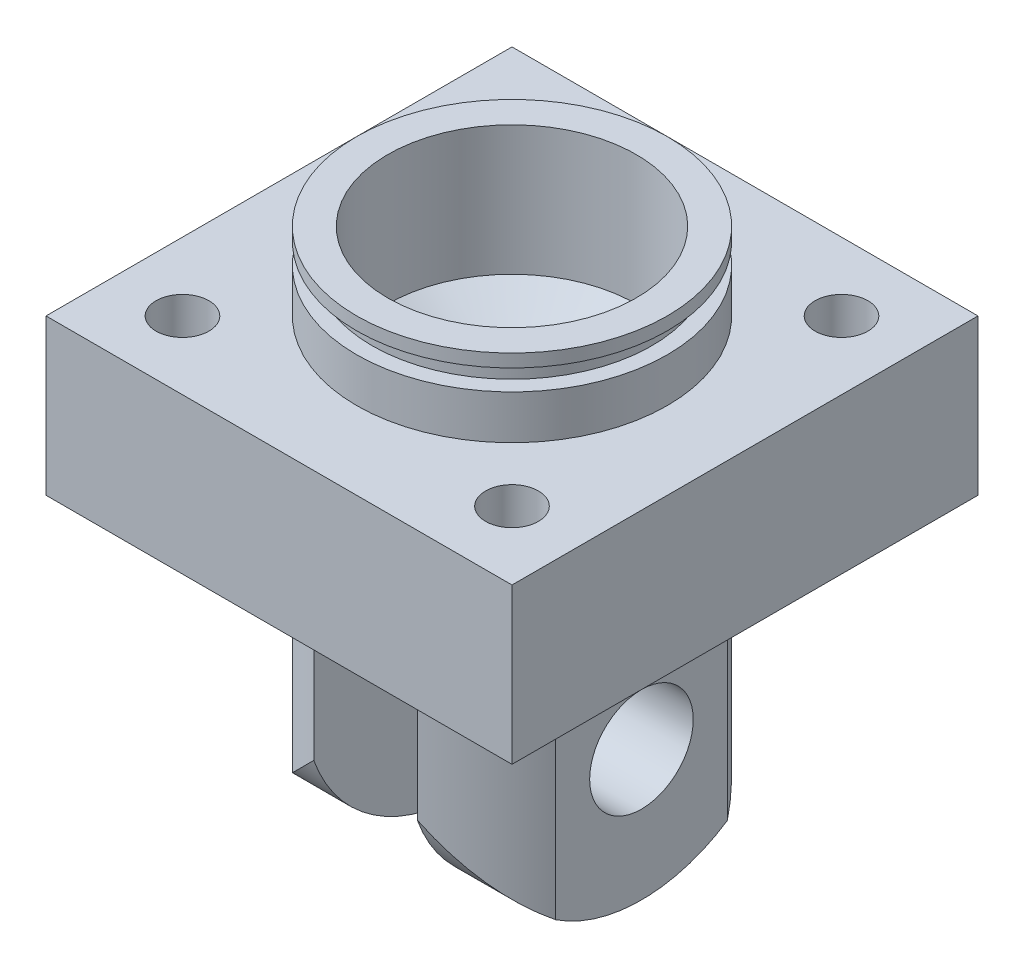
from build123d import *

# Parameters (mm, degrees)
SKETCH1_W                          = 90
SKETCH1_H                          = 90
BOSS_EXTRUDE1_DEPTH                = 15
SKETCH2_R                          = 30
BOSS_EXTRUDE2_DEPTH                = 8.5
SKETCH3_R                          = 27
BOSS_EXTRUDE3_DEPTH                = 4
SKETCH4_R                          = 30
BOSS_EXTRUDE4_DEPTH                = 2.5
BOSS_EXTRUDE5_START                = 55.2
SKETCH5_R                          = 30
BOSS_EXTRUDE5_DEPTH                = 55.2
CUT_EXTRUDE1_DEPTH                 = 95.752519755
CUT_EXTRUDE1_DEPTH_BACK            = 95.752519755
SKETCH6_R                          = 10
SKETCH7_W                          = 20
SKETCH7_H                          = 64.311961004
CUT_EXTRUDE2_DEPTH                 = 55.2
SKETCH8_OUTSIDE_W                  = 124.398
SKETCH8_OUTSIDE_H                  = 124.398
SKETCH8_OUTSIDE_W_2                = 50
SKETCH8_OUTSIDE_H_2                = 73.670791152
CUT_EXTRUDE3_DEPTH                 = 60
CUT_EXTRUDE5_DEPTH                 = 109.871667572
CUT_EXTRUDE5_DEPTH_BACK            = 109.871667572
TAP_DRILL_FOR_M1_2X0_25_TAP1_D     = 48
TAP_DRILL_FOR_M1_2X0_25_TAP1_DEPTH = 25
TAP_DRILL_FOR_M1_2X0_25_TAP1_TIP   = 14.420654857
CIRPATTERN1_COUNT                  = 4
M16X1_5_TAPPED_HOLE1_D             = 14.5
M16X1_5_TAPPED_HOLE1_DEPTH         = 16
M16X1_5_TAPPED_HOLE1_TIP           = 4.356239488
SKETCH18_R                         = 1.7
CUT_EXTRUDE6_DEPTH                 = 46


with BuildPart() as part:
    # Sketch1 → Boss-Extrude1 (new, symmetric)
    with BuildSketch(Plane(origin=(0, 0, 0), x_dir=(1, 0, 0), z_dir=(0, 1, 0))):
        Rectangle(SKETCH1_W, SKETCH1_H)
    extrude(amount=BOSS_EXTRUDE1_DEPTH, both=True)

    # Sketch2 → Boss-Extrude2 (add)
    with BuildSketch(Plane(origin=(0, 15, 0), x_dir=(1, 0, 0), z_dir=(0, 1, 0))):
        Circle(SKETCH2_R)
    extrude(amount=BOSS_EXTRUDE2_DEPTH)

    # Sketch3 → Boss-Extrude3 (add)
    with BuildSketch(Plane(origin=(0, 23.5, 0), x_dir=(1, 0, 0), z_dir=(0, 1, 0))):
        Circle(SKETCH3_R)
    extrude(amount=BOSS_EXTRUDE3_DEPTH)

    # Sketch4 → Boss-Extrude4 (add)
    with BuildSketch(Plane(origin=(0, 27.5, 0), x_dir=(1, 0, 0), z_dir=(0, 1, 0))):
        Circle(SKETCH4_R)
    extrude(amount=BOSS_EXTRUDE4_DEPTH)

    # Sketch5 → Boss-Extrude5 (add)
    with BuildSketch(Plane(origin=(0, -15, 0), x_dir=(-1, 0, 0), z_dir=(0, -1, 0)).offset(BOSS_EXTRUDE5_START)):
        Circle(SKETCH5_R)
    extrude(amount=-BOSS_EXTRUDE5_DEPTH)

    # Sketch6 → Cut-Extrude1 (cut, two sides: drawn at the far end of the back side and taken through both)
    with BuildSketch(Plane(origin=(0, 0, 0), x_dir=(0, 0, -1), z_dir=(1, 0, 0)).offset(-CUT_EXTRUDE1_DEPTH_BACK)):
        with Locations((0, -45)):
            Circle(SKETCH6_R)
    extrude(amount=CUT_EXTRUDE1_DEPTH + CUT_EXTRUDE1_DEPTH_BACK, mode=Mode.SUBTRACT)

    # Sketch7 → Cut-Extrude2 (cut)
    with BuildSketch(Plane(origin=(0, -70.2, 0), x_dir=(-1, 0, 0), z_dir=(0, -1, 0))):
        Rectangle(SKETCH7_W, SKETCH7_H)
    extrude(amount=-CUT_EXTRUDE2_DEPTH, mode=Mode.SUBTRACT)

    # Sketch8 outside → Cut-Extrude3 (cut)
    with BuildSketch(Plane(origin=(0, -15, 0), x_dir=(-1, 0, 0), z_dir=(0, -1, 0))):
        Rectangle(SKETCH8_OUTSIDE_W, SKETCH8_OUTSIDE_H)
        Rectangle(SKETCH8_OUTSIDE_W_2, SKETCH8_OUTSIDE_H_2, mode=Mode.SUBTRACT)
    extrude(amount=CUT_EXTRUDE3_DEPTH, mode=Mode.SUBTRACT)

    # Sketch10 → Cut-Extrude5 (cut, two sides: drawn at the far end of the back side and taken through both)
    with BuildSketch(Plane(origin=(25, 0, 0), x_dir=(0, 0, -1), z_dir=(1, 0, 0)).offset(-CUT_EXTRUDE5_DEPTH_BACK)):
        with BuildLine():
            Line((-28.284271247, -82.924550927), (28.284271247, -82.924550927))
            Line((28.284271247, -82.924550927), (28.284271247, -50.2))
            ThreePointArc((28.284271247, -50.2), (0, -70.2), (-28.284271247, -50.2))
            Line((-28.284271247, -50.2), (-28.284271247, -82.924550927))
        make_face()
    extrude(amount=CUT_EXTRUDE5_DEPTH + CUT_EXTRUDE5_DEPTH_BACK, mode=Mode.SUBTRACT)

    # Tap Drill for M1.2x0.25 Tap1
    with Locations(Plane.ZX.offset(30)):
        with Locations((0, 0)):
            Hole(TAP_DRILL_FOR_M1_2X0_25_TAP1_D / 2, depth=TAP_DRILL_FOR_M1_2X0_25_TAP1_DEPTH)
            with Locations((0, 0, -(TAP_DRILL_FOR_M1_2X0_25_TAP1_DEPTH + TAP_DRILL_FOR_M1_2X0_25_TAP1_TIP / 2))):  # 118° drill point
                Cone(0, TAP_DRILL_FOR_M1_2X0_25_TAP1_D / 2, TAP_DRILL_FOR_M1_2X0_25_TAP1_TIP, mode=Mode.SUBTRACT)

    # Sketch15 → M12 Tapped Hole1 (revolve, cut)
    with BuildSketch(Plane(origin=(31.819805153, 15, -31.819805153), x_dir=(0, 0, 1), z_dir=(1, 0, 0))):
        Polygon((0, 0), (0, 23.064389157), (5.1, 20), (5.1, 0), align=None)
    m12_tapped_hole1 = revolve(axis=Axis((31.819805153, 21.35, -31.819805153), (0, -1, 0)), mode=Mode.SUBTRACT)

    # CirPattern1: M12 Tapped Hole1 ×4 about axis
    cirpattern1_axis = Axis((0, 64.33779776, 0), (0, -1, 0))
    for i in range(1, CIRPATTERN1_COUNT):
        add(m12_tapped_hole1.rotate(cirpattern1_axis, i * 360 / CIRPATTERN1_COUNT), mode=Mode.SUBTRACT)

    # M16x1.5 Tapped Hole1
    with Locations(Plane(origin=(0, 0, -45), x_dir=(-1, 0, 0), z_dir=(0, 0, -1))):
        with Locations((0, 0)):
            Hole(M16X1_5_TAPPED_HOLE1_D / 2, depth=M16X1_5_TAPPED_HOLE1_DEPTH)
            with Locations((0, 0, -(M16X1_5_TAPPED_HOLE1_DEPTH + M16X1_5_TAPPED_HOLE1_TIP / 2))):  # 118° drill point
                Cone(0, M16X1_5_TAPPED_HOLE1_D / 2, M16X1_5_TAPPED_HOLE1_TIP, mode=Mode.SUBTRACT)

    # Sketch18 → Cut-Extrude6 (cut)
    with BuildSketch(Plane(origin=(0, 0, -45), x_dir=(-1, 0, 0), z_dir=(0, 0, -1))):
        Circle(SKETCH18_R)
    extrude(amount=-CUT_EXTRUDE6_DEPTH, mode=Mode.SUBTRACT)


solid = part.part
